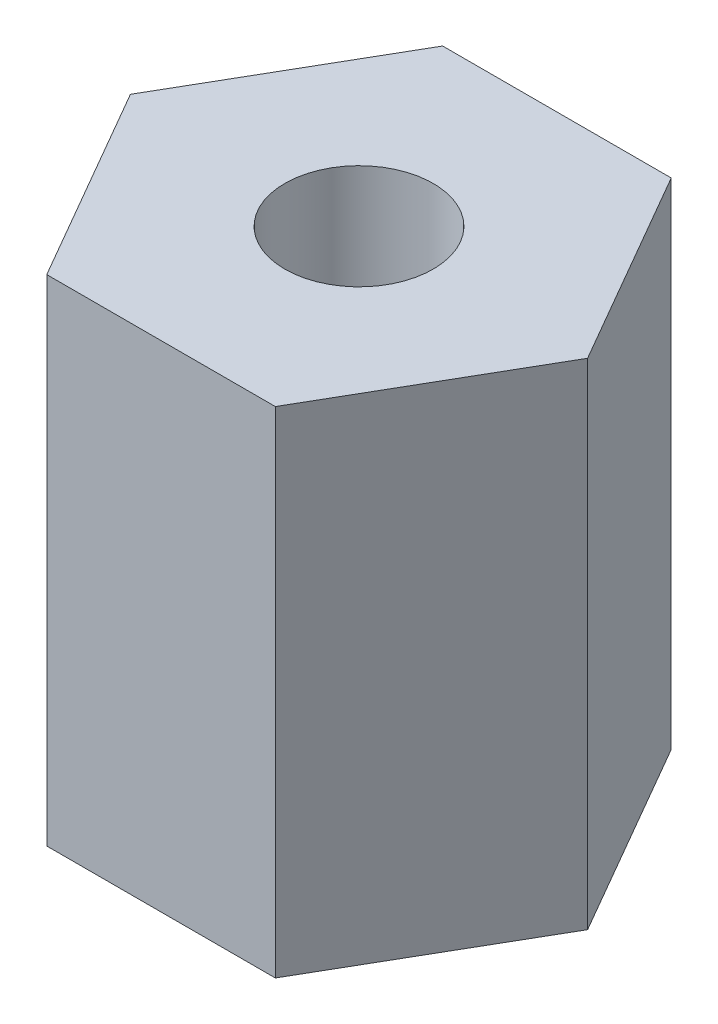
from build123d import *

# Parameters (mm, degrees)
SKETCH1_R           = 1.5
BOSS_EXTRUDE1_DEPTH = 10


with BuildPart() as part:
    # Sketch1 → Boss-Extrude1 (new body)
    with BuildSketch(Plane(origin=(0, 0, 0), x_dir=(1, 0, 0), z_dir=(0, 1, 0))):
        Polygon((4.618802154, 0), (2.309401077, 4), (-2.309401077, 4), (-4.618802154, 0), (-2.309401077, -4), (2.309401077, -4), align=None)
        Circle(SKETCH1_R, mode=Mode.SUBTRACT)
    extrude(amount=BOSS_EXTRUDE1_DEPTH)


solid = part.part
